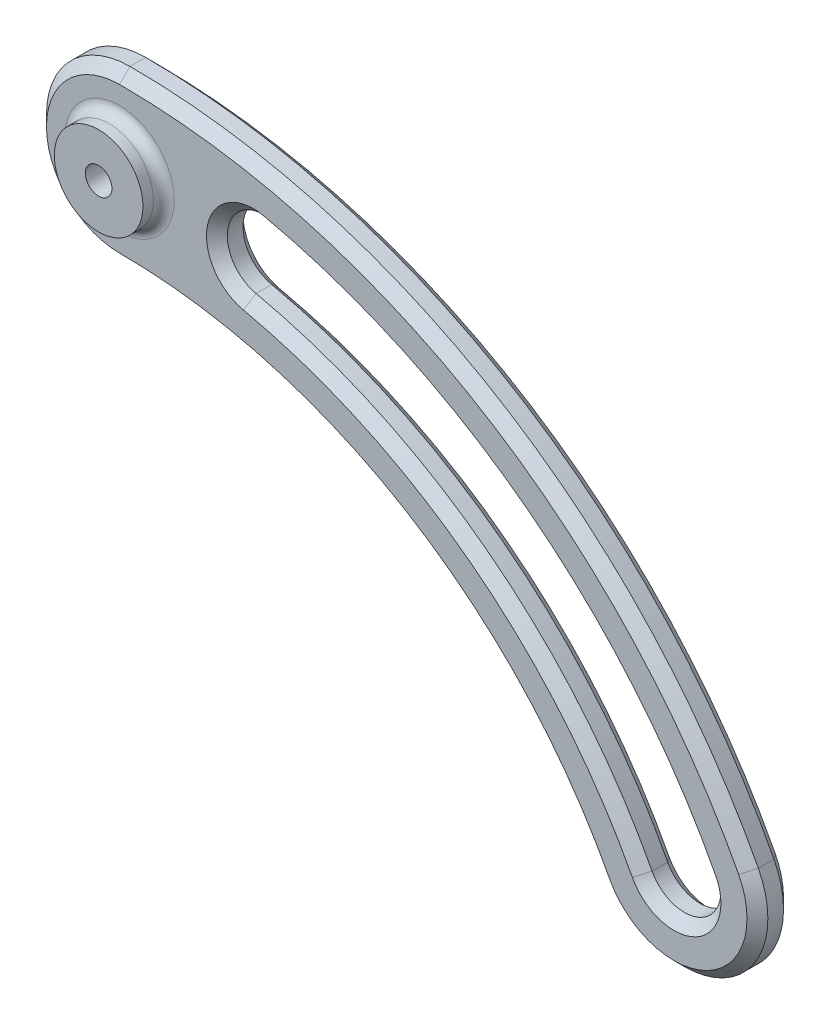
from build123d import *

# Parameters (mm, degrees)
SKETCH1_R           = 8.5
SKETCH1_R_2         = 2.55
BOSS_EXTRUDE1_DEPTH = 7
BOSS_EXTRUDE2_START = 7
SKETCH1_3_R         = 8.5
SKETCH1_3_R_2       = 2.55
BOSS_EXTRUDE2_DEPTH = 4
CHAMFER1_SIZE       = 2
FILLET2_R           = 2
CUT_EXTRUDE1_START  = -9
SKETCH2_R           = 5.25
CUT_EXTRUDE1_DEPTH  = 2


with BuildPart() as part:
    # Sketch1 → Boss-Extrude1 (new body)
    with BuildSketch(Plane.XY):
        with BuildLine():
            ThreePointArc((92.127210642, -71.744668074), (53.839787702, -31.020916727), (0, -16))
            ThreePointArc((0, -16), (-16, 0), (0, 16))
            ThreePointArc((0, 16), (70.405876226, -3.642737258), (120.474044686, -56.896873635))
            ThreePointArc((120.474044686, -56.896873635), (113.724524883, -78.494187876), (92.127210642, -71.744668074))
        make_face()
        Circle(SKETCH1_R, mode=Mode.SUBTRACT)
        with BuildLine():
            ThreePointArc((112.501497611, -61.072815821), (77.057279191, -19.048646747), (27.173726746, 4.058810952))
            ThreePointArc((27.173726746, 4.058810952), (18.838075062, -1.2813118), (24.178197814, -9.616963484))
            ThreePointArc((24.178197814, -9.616963484), (68.562775973, -30.177142381), (100.099757717, -67.568725888))
            ThreePointArc((100.099757717, -67.568725888), (109.548582697, -70.521640801), (112.501497611, -61.072815821))
        make_face(mode=Mode.SUBTRACT)
        Circle(SKETCH1_R)
        Circle(SKETCH1_R_2, mode=Mode.SUBTRACT)
    extrude(amount=BOSS_EXTRUDE1_DEPTH)

    # Sketch1_3 → Boss-Extrude2 (add)
    with BuildSketch(Plane.XY.offset(BOSS_EXTRUDE2_START)):
        Circle(SKETCH1_3_R)
        Circle(SKETCH1_3_R_2, mode=Mode.SUBTRACT)
    extrude(amount=BOSS_EXTRUDE2_DEPTH)

    # Chamfer1
    chamfer1_edges = [part.edges().sort_by_distance(p)[0] for p in [
        (113.724524883, -78.494187876, 7),
        (18.838075062, -1.2813118, 0),
        (68.562775973, -30.177142381, 0),
        (109.548582697, -70.521640801, 0),
        (77.057279191, -19.048646747, 0),
        (-16, 0, 0),
        (70.405876226, -3.642737258, 0),
        (113.724524883, -78.494187876, 0),
        (70.405876226, -3.642737258, 7),
        (53.839787702, -31.020916727, 0),
        (-16, 0, 7),
        (77.057279191, -19.048646747, 7),
        (109.548582697, -70.521640801, 7),
        (68.562775973, -30.177142381, 7),
        (18.838075062, -1.2813118, 7),
        (53.839787702, -31.020916727, 7),
    ]]
    chamfer(chamfer1_edges, length=CHAMFER1_SIZE)

    # Fillet2
    fillet2_edges = [part.edges().sort_by_distance(p)[0] for p in [
        (-8.5, 0, 7),
    ]]
    fillet(fillet2_edges, radius=FILLET2_R)

    # Sketch2 → Cut-Extrude1 (cut)
    with BuildSketch(Plane.XY.offset(11).offset(CUT_EXTRUDE1_START)):
        Circle(SKETCH2_R)
    extrude(amount=-CUT_EXTRUDE1_DEPTH, mode=Mode.SUBTRACT)


solid = part.part
